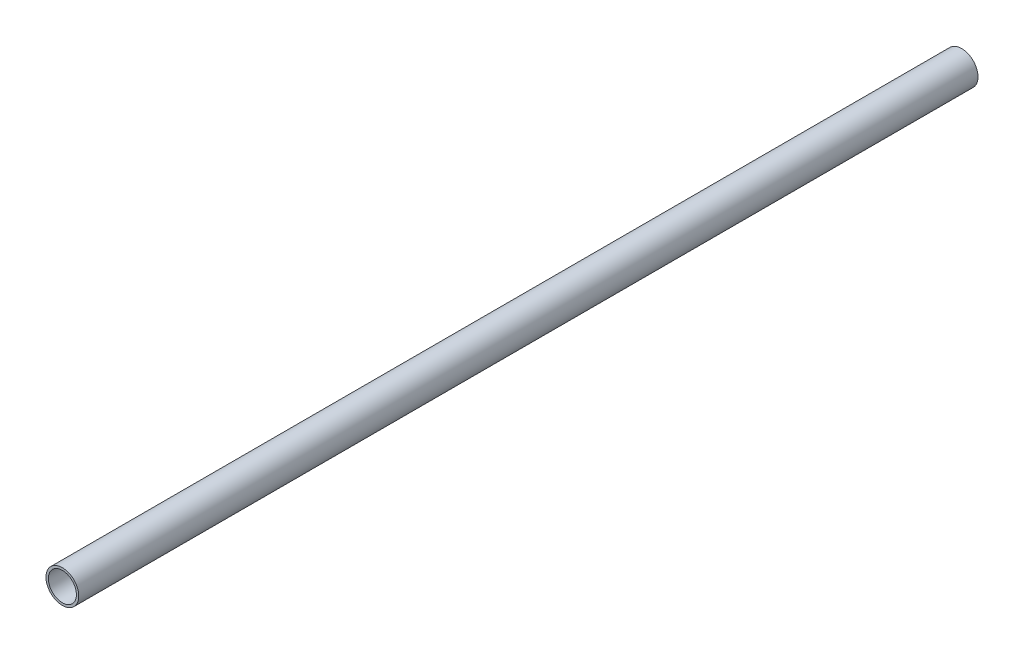
from build123d import *

# Parameters (mm, degrees)
SKETCH1_R           = 11.1125
SKETCH1_R_2         = 9.525
BOSS_EXTRUDE1_DEPTH = 304.8


with BuildPart() as part:
    # Sketch1 → Boss-Extrude1 (new body, symmetric)
    with BuildSketch(Plane.XY):
        Circle(SKETCH1_R)
        Circle(SKETCH1_R_2, mode=Mode.SUBTRACT)
    extrude(amount=BOSS_EXTRUDE1_DEPTH, both=True)


solid = part.part
